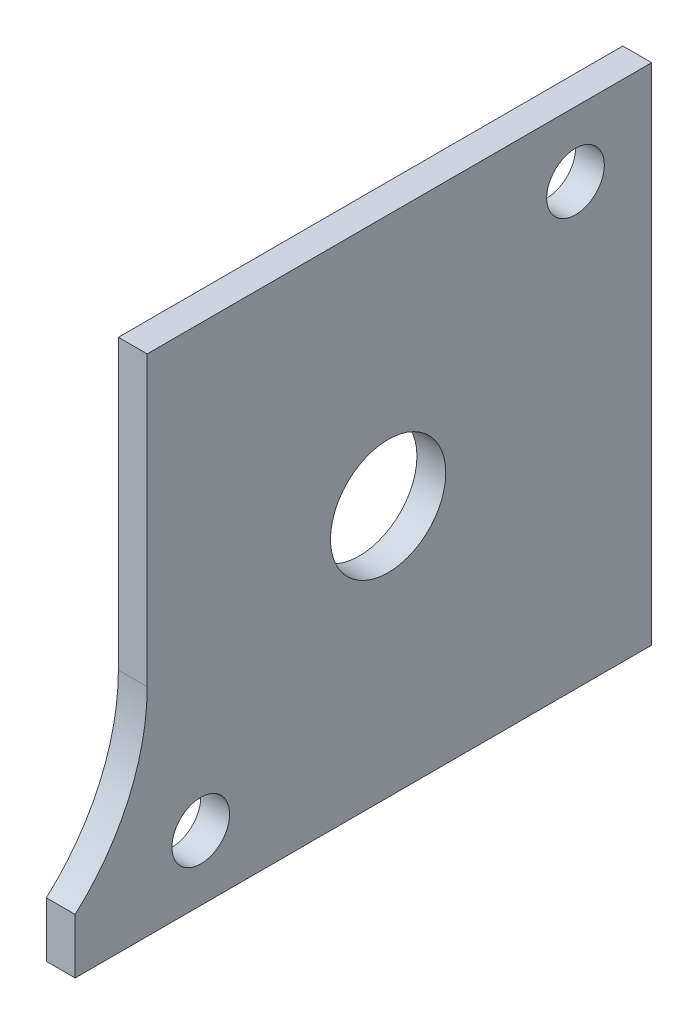
from build123d import *

# Parameters (mm, degrees)
SKETCH1_R           = 4
SKETCH1_R_2         = 2
BOSS_EXTRUDE1_DEPTH = 2


with BuildPart() as part:
    # Sketch1 → Boss-Extrude1 (new body)
    with BuildSketch(Plane(origin=(0, 0, 0), x_dir=(0, 0, -1), z_dir=(1, 0, 0))):
        with BuildLine():
            Line((121.29692104, -40.99299677), (121.29692104, -5.99299677))
            Line((121.29692104, -5.99299677), (86.29692104, -5.99299677))
            Line((86.29692104, -5.99299677), (86.29692104, -25.99299677))
            ThreePointArc((86.29692104, -25.99299677), (84.989984977, -32.116721127), (81.29692104, -37.173336658))
            Line((81.29692104, -37.173336658), (81.29692104, -40.99299677))
            Line((81.29692104, -40.99299677), (121.29692104, -40.99299677))
        make_face()
        with Locations((103.011400413, -23.49299677)):
            Circle(SKETCH1_R, mode=Mode.SUBTRACT)
        with Locations((116.011400413, -10.49299677)):
            Circle(SKETCH1_R_2, mode=Mode.SUBTRACT)
        with Locations((90.011400413, -36.49299677)):
            Circle(SKETCH1_R_2, mode=Mode.SUBTRACT)
    extrude(amount=BOSS_EXTRUDE1_DEPTH)


solid = part.part
